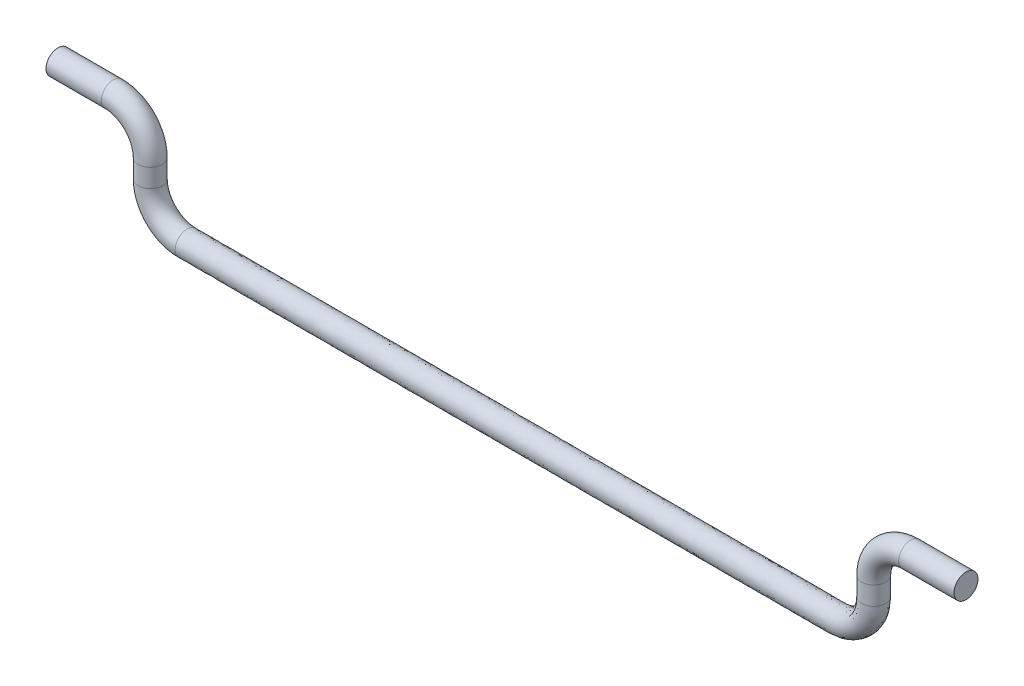
from build123d import *

# Parameters (mm, degrees)
SKETCH2_R = 0.65


with BuildPart() as part:
    # Sweep1: sweep along a path in Sketch1
    with BuildLine(Plane.XY) as sweep1_path:
        Line((-7, 5), (-4, 5))
        ThreePointArc((-4, 5), (-2.585786438, 4.414213562), (-2, 3))
        Line((-2, 3), (-2, 2))
        ThreePointArc((-2, 2), (-1.414213562, 0.585786438), (0, 0))
        Line((0, 0), (35.2, 0))
        ThreePointArc((35.2, 0), (36.614213562, 0.585786438), (37.2, 2))
        Line((37.2, 2), (37.2, 3))
        ThreePointArc((37.2, 3), (37.785786438, 4.414213562), (39.2, 5))
        Line((39.2, 5), (42.2, 5))
    # Sketch2 → Sweep1 (sweep)
    with BuildSketch(Plane(origin=(35.2, 0, 0), x_dir=(0, 0, -1), z_dir=(1, 0, 0))):
        Circle(SKETCH2_R)
    sweep(path=sweep1_path.line)


solid = part.part
